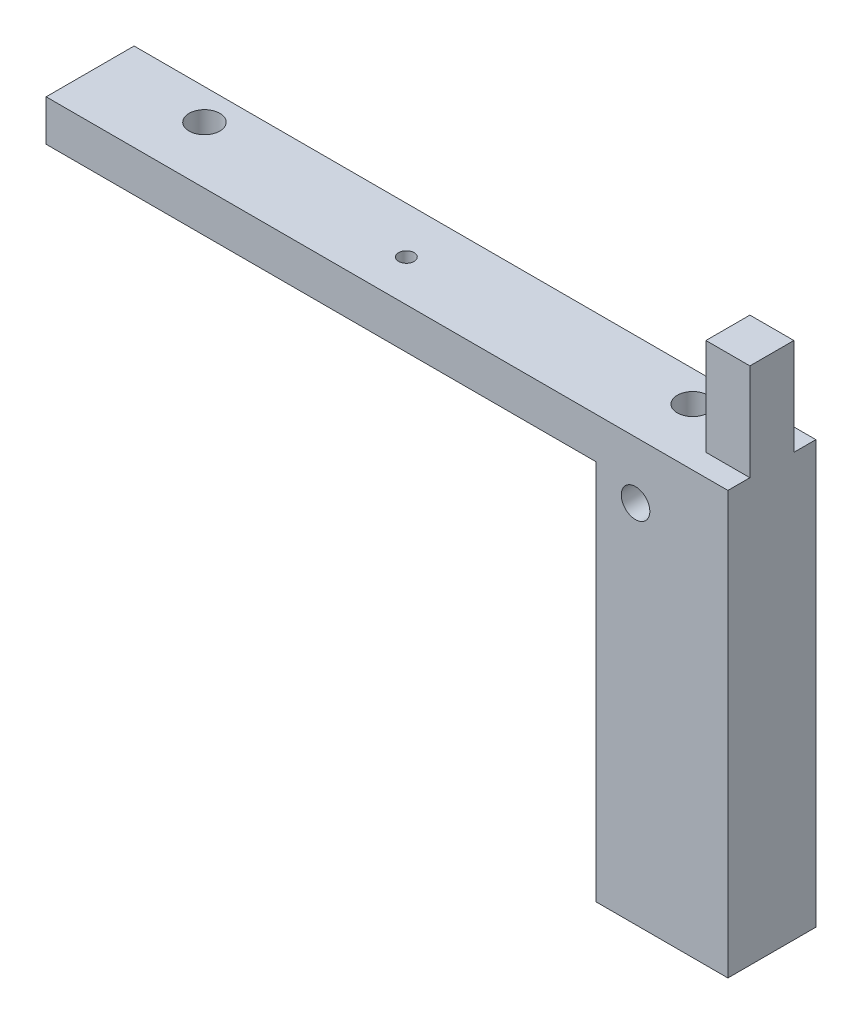
from build123d import *

# Parameters (mm, degrees)
BOSS_EXTRUDE3_DEPTH     = 10
SKETCH5_W               = 30
SKETCH5_H               = 25
BOSS_EXTRUDE5_DEPTH     = 5
BOSS_EXTRUDE7_DEPTH     = 5
BOSS_EXTRUDE8_DEPTH     = 71
BOSS_EXTRUDE9_DEPTH     = 125
SKETCH12_R              = 3.25
CUT_EXTRUDE1_DEPTH      = 6
CUT_EXTRUDE1_DEPTH_BACK = 15
SKETCH13_R              = 1.75
CUT_EXTRUDE2_DEPTH      = 5
CUT_EXTRUDE2_DEPTH_BACK = 15
SKETCH14_R              = 3.5
CUT_EXTRUDE3_DEPTH      = 10
SKETCH15_R              = 3.5
CUT_EXTRUDE4_DEPTH      = 10


with BuildPart() as part:
    # Sketch3 → Boss-Extrude3 (new body)
    with BuildSketch(Plane.XY):
        Polygon((0, 0), (0, -5), (20, -5), (20, -25), (30, -25), (30, 22.02), (20, 22.02), (20, 0), align=None)
    extrude(amount=BOSS_EXTRUDE3_DEPTH)

    # Sketch5 → Boss-Extrude5 (add)
    with BuildSketch(Plane.XY.offset(10)):
        with Locations((15, -12.5)):
            Rectangle(SKETCH5_W, SKETCH5_H)
    extrude(amount=BOSS_EXTRUDE5_DEPTH)

    # Sketch7 → Boss-Extrude7 (add)
    with BuildSketch(Plane(origin=(0, 0, 0), x_dir=(-1, 0, 0), z_dir=(0, 0, -1))):
        Polygon((0, 0), (-20, 0), (-20.758888401, 0), (-30, 0), (-30, -25), (-20, -25), (-20, -5), (0, -5), align=None)
    extrude(amount=BOSS_EXTRUDE7_DEPTH)

    # Sketch10 → Boss-Extrude8 (add)
    with BuildSketch(Plane.XZ.offset(25)):
        Polygon((0, 10), (20, 10), (20, -5), (30, -5), (30, 15), (0, 15), align=None)
    extrude(amount=BOSS_EXTRUDE8_DEPTH)

    # Sketch11 → Boss-Extrude9 (add)
    with BuildSketch(Plane.ZY):
        Polygon((10, 0), (-5, 0), (-5, -5), (10, -5), (10, -9.348527433), (15, -9.348527433), (15, -5), (15, 0), align=None)
    extrude(amount=BOSS_EXTRUDE9_DEPTH)

    # Sketch12 → Cut-Extrude1 (cut, two sides)
    with BuildSketch(Plane.XY.offset(15)) as cut_extrude1_sk:
        with Locations((9, -13)):
            Circle(SKETCH12_R)
    extrude(amount=CUT_EXTRUDE1_DEPTH, mode=Mode.SUBTRACT)
    extrude(cut_extrude1_sk.sketch, amount=-CUT_EXTRUDE1_DEPTH_BACK, mode=Mode.SUBTRACT)

    # Sketch13 → Cut-Extrude2 (cut, two sides)
    with BuildSketch(Plane(origin=(0, 0, 0), x_dir=(1, 0, 0), z_dir=(0, 1, 0))) as cut_extrude2_sk:
        with Locations((-52.5, -5.597603222)):
            Circle(SKETCH13_R)
    extrude(amount=CUT_EXTRUDE2_DEPTH, mode=Mode.SUBTRACT)
    extrude(cut_extrude2_sk.sketch, amount=-CUT_EXTRUDE2_DEPTH_BACK, mode=Mode.SUBTRACT)

    # Sketch14 → Cut-Extrude3 (cut)
    with BuildSketch(Plane(origin=(0, 0, 0), x_dir=(1, 0, 0), z_dir=(0, 1, 0))):
        with Locations((-102, -2)):
            Circle(SKETCH14_R)
    extrude(amount=-CUT_EXTRUDE3_DEPTH, mode=Mode.SUBTRACT)

    # Sketch15 → Cut-Extrude4 (cut)
    with BuildSketch(Plane(origin=(0, 0, 0), x_dir=(1, 0, 0), z_dir=(0, 1, 0))):
        with Locations((9, -2)):
            Circle(SKETCH15_R)
    extrude(amount=-CUT_EXTRUDE4_DEPTH, mode=Mode.SUBTRACT)


solid = part.part
